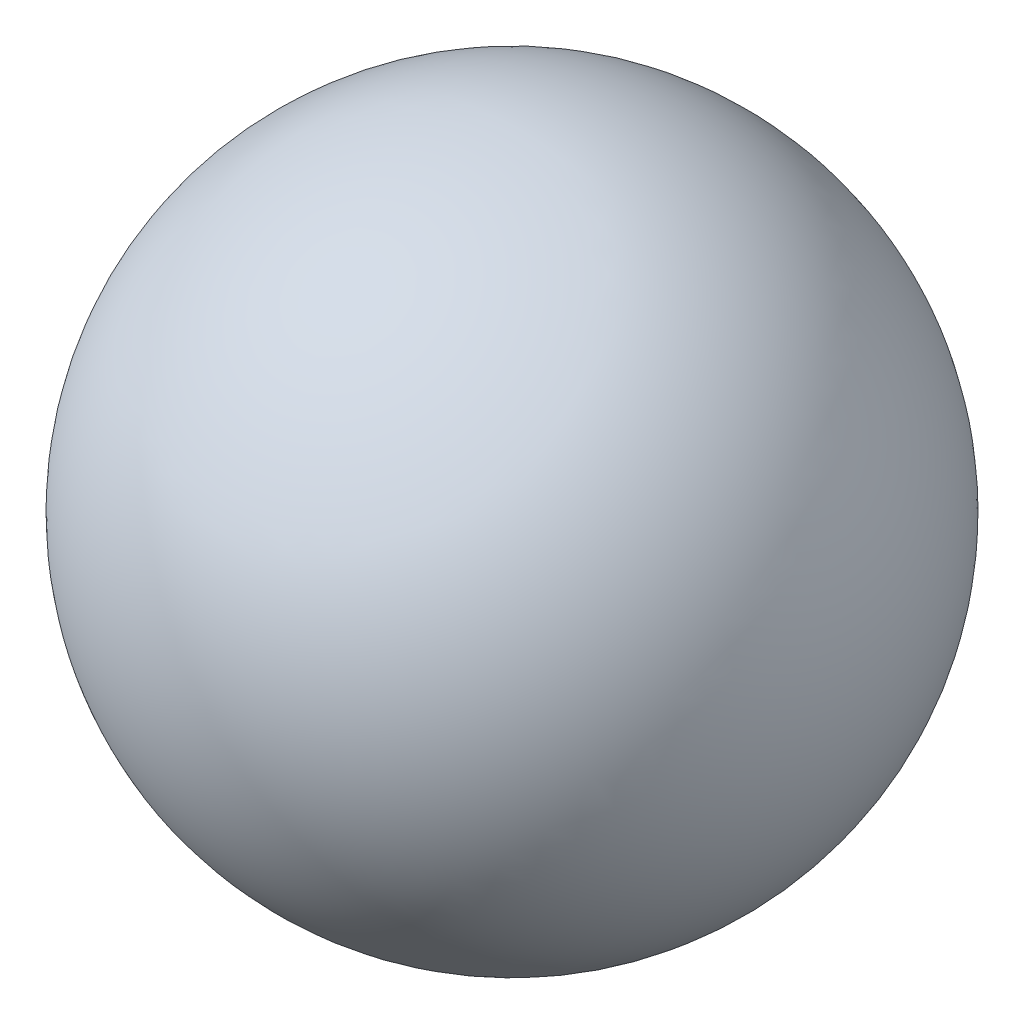
from build123d import *

# Parameters (mm, degrees)
M3X0_5_TAPPED_HOLE1_D           = 2.5
M3X0_5_TAPPED_HOLE1_DEPTH       = 5
M3X0_5_TAPPED_HOLE1_CSINK_D     = 3.05
M3X0_5_TAPPED_HOLE1_CSINK_ANGLE = 90
M3X0_5_TAPPED_HOLE1_TIP         = 0.751075774


with BuildPart() as part:
    # Sketch2 → Revolve1 (revolve)
    with BuildSketch(Plane.XY):
        with BuildLine():
            Line((0, 8), (0, 0))
            ThreePointArc((0, 0), (4, 4), (0, 8))
        make_face()
    revolve(axis=Axis((0, 0, 0), (0, 1, 0)))

    # M3x0.5 Tapped Hole1
    with Locations(Plane(origin=(0, 0, -4), x_dir=(-1, 0, 0), z_dir=(0, 0, -1))):
        with Locations((0, 4)):
            CounterSinkHole(M3X0_5_TAPPED_HOLE1_D / 2, M3X0_5_TAPPED_HOLE1_CSINK_D / 2, depth=M3X0_5_TAPPED_HOLE1_DEPTH, counter_sink_angle=M3X0_5_TAPPED_HOLE1_CSINK_ANGLE)
            with Locations((0, 0, -(M3X0_5_TAPPED_HOLE1_DEPTH + M3X0_5_TAPPED_HOLE1_TIP / 2))):  # 118° drill point
                Cone(0, M3X0_5_TAPPED_HOLE1_D / 2, M3X0_5_TAPPED_HOLE1_TIP, mode=Mode.SUBTRACT)


solid = part.part
